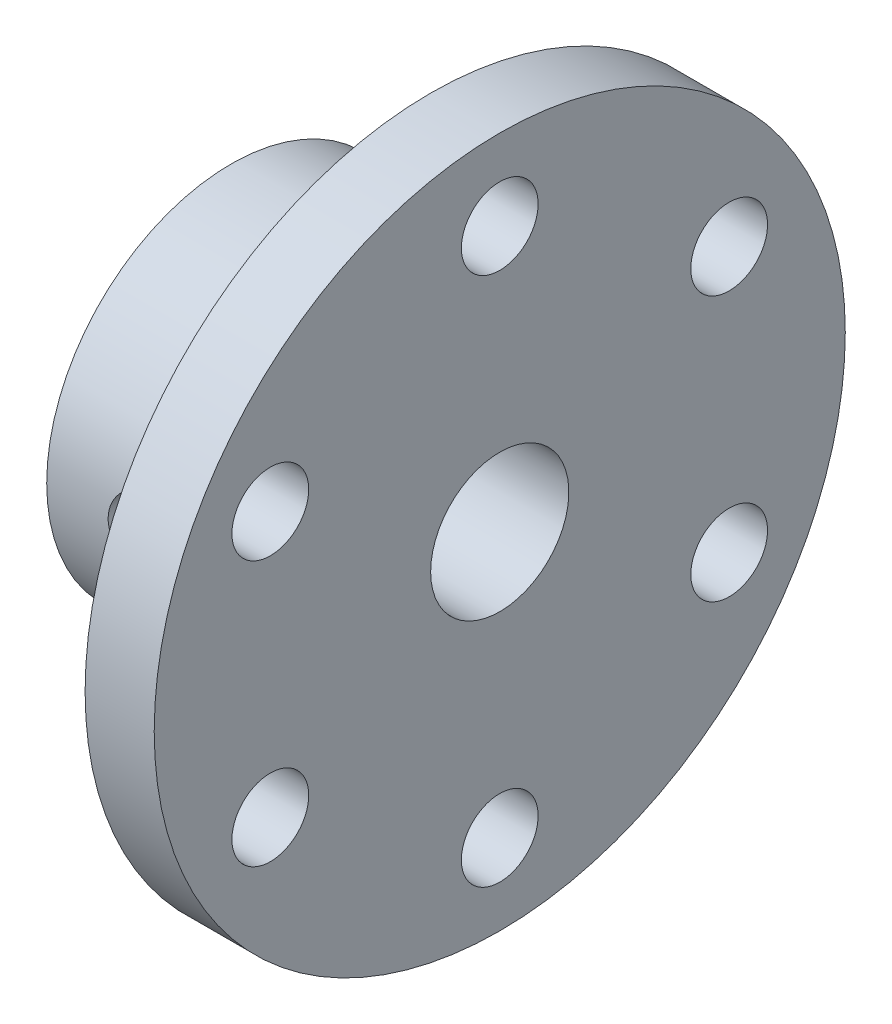
from build123d import *

# Parameters (mm, degrees)
SKETCH2_R          = 2.5
CUT_EXTRUDE1_DEPTH = 4.5
CUT_EXTRUDE2_REACH = 36.5
SKETCH3_R          = 2.5


with BuildPart() as part:
    # Sketch1 → Revolve1 (revolve)
    with BuildSketch(Plane.XY):
        Polygon((-14.700460829, 4.5), (-14.700460829, 12), (-1.700460829, 12), (-1.700460829, 22.5), (2.799539171, 22.5), (2.799539171, 4.5), align=None)
    revolve(axis=Axis((-11.612903226, 0, 0), (1, 0, 0)))

    # Sketch2 → Cut-Extrude1 (cut)
    with BuildSketch(Plane.ZY.offset(1.700460829)):
        with Locations((0, 17.25)):
            Circle(SKETCH2_R)
        with Locations((14.938938215, 8.625)):
            Circle(SKETCH2_R)
        with Locations((14.938938215, -8.625)):
            Circle(SKETCH2_R)
        with Locations((0, -17.25)):
            Circle(SKETCH2_R)
        with Locations((-14.938938215, -8.625)):
            Circle(SKETCH2_R)
        with Locations((-14.938938215, 8.625)):
            Circle(SKETCH2_R)
    extrude(amount=-CUT_EXTRUDE1_DEPTH, mode=Mode.SUBTRACT)

    # Sketch3 → Cut-Extrude2 (cut, up to next)
    with BuildSketch(Plane.XY.offset(12), mode=Mode.PRIVATE) as cut_extrude2_sk1:
        with Locations((-8.200460829, 0)):
            Circle(SKETCH3_R)
    cut_extrude2_tool1 = extrude(cut_extrude2_sk1.sketch, amount=-CUT_EXTRUDE2_REACH, mode=Mode.PRIVATE) & part.part
    add(cut_extrude2_tool1.solids().sort_by_distance((-8.200461, 0, 12))[0], mode=Mode.SUBTRACT)


solid = part.part
